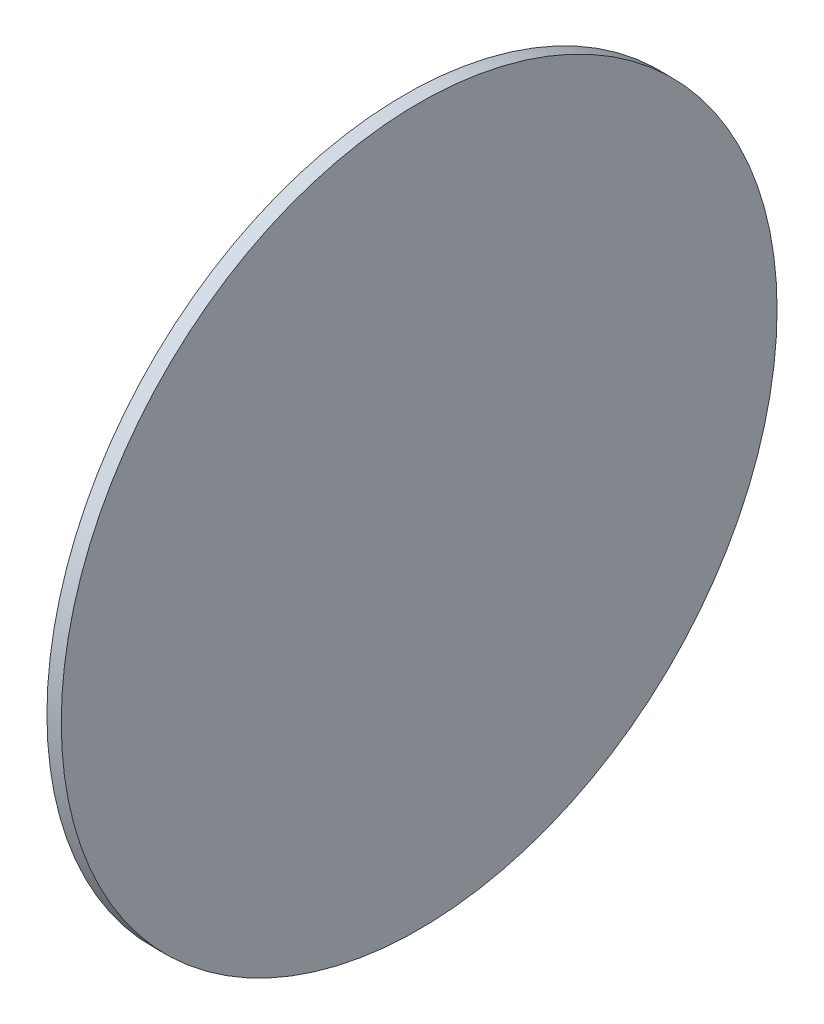
from build123d import *

# Parameters (mm, degrees)
SKETCH1_R           = 250
BOSS_EXTRUDE1_DEPTH = 10


with BuildPart() as part:
    # Sketch1 → Boss-Extrude1 (new body)
    with BuildSketch(Plane(origin=(0, 0, 0), x_dir=(0, 0, -1), z_dir=(1, 0, 0))):
        Circle(SKETCH1_R)
    extrude(amount=BOSS_EXTRUDE1_DEPTH)


solid = part.part
